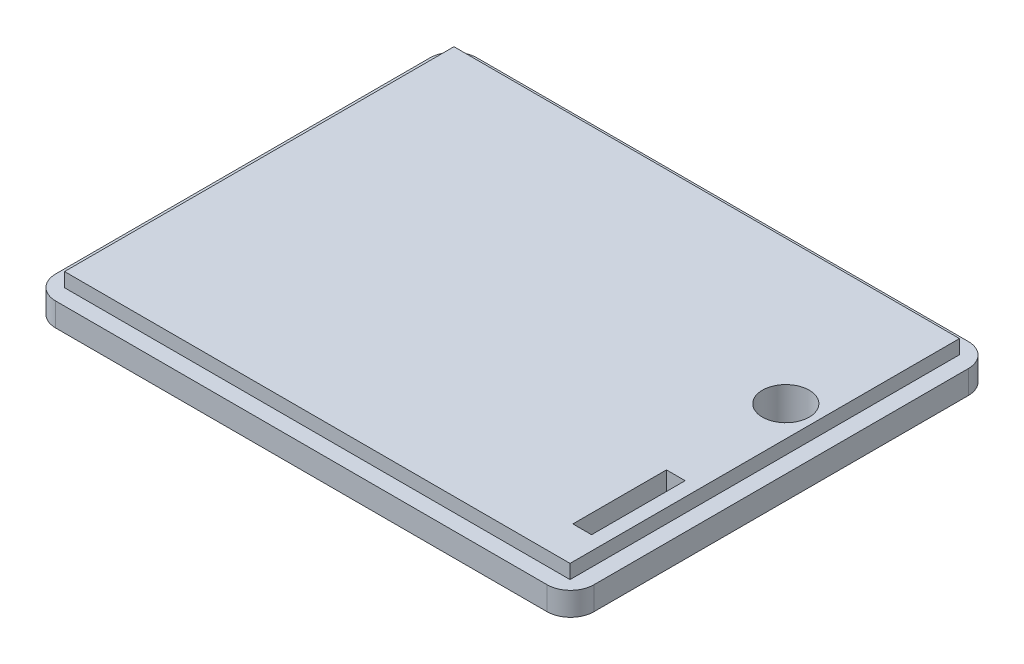
from build123d import *

# Parameters (mm, degrees)
SKETCH1_W           = 115
SKETCH1_H           = 90
BOSS_EXTRUDE1_DEPTH = 5
SKETCH2_W           = 108
SKETCH2_H           = 83.2
BOSS_EXTRUDE2_DEPTH = 3
FILLET1_R           = 5
SKETCH3_W           = 4
SKETCH3_H           = 20
CUT_EXTRUDE1_DEPTH  = 10
FILLET2_R           = 1
SKETCH4_R           = 5
CUT_EXTRUDE2_DEPTH  = 10
FILLET3_R           = 1


with BuildPart() as part:
    # Sketch1 → Boss-Extrude1 (new body)
    with BuildSketch(Plane(origin=(0, 0, 0), x_dir=(1, 0, 0), z_dir=(0, 1, 0))):
        Rectangle(SKETCH1_W, SKETCH1_H)
    extrude(amount=BOSS_EXTRUDE1_DEPTH)

    # Sketch2 → Boss-Extrude2 (add)
    with BuildSketch(Plane(origin=(0, 5, 0), x_dir=(1, 0, 0), z_dir=(0, 1, 0))):
        Rectangle(SKETCH2_W, SKETCH2_H)
    extrude(amount=BOSS_EXTRUDE2_DEPTH)

    # Fillet1
    fillet1_edges = [part.edges().sort_by_distance(p)[0] for p in [
        (57.5, 2.5, 45),
        (-57.5, 2.5, 45),
        (-57.5, 2.5, -45),
        (57.5, 2.5, -45),
    ]]
    fillet(fillet1_edges, radius=FILLET1_R)

    # Sketch3 → Cut-Extrude1 (cut)
    with BuildSketch(Plane(origin=(0, 0, 0), x_dir=(-1, 0, 0), z_dir=(0, -1, 0))):
        with Locations((-49, -24)):
            Rectangle(SKETCH3_W, SKETCH3_H)
    extrude(amount=-CUT_EXTRUDE1_DEPTH, mode=Mode.SUBTRACT)

    # Fillet2
    fillet2_edges = [part.edges().sort_by_distance(p)[0] for p in [
        (47, 0, 24),
        (49, 0, 14),
        (51, 0, 24),
        (49, 0, 34),
    ]]
    fillet(fillet2_edges, radius=FILLET2_R)

    # Sketch4 → Cut-Extrude2 (cut)
    with BuildSketch(Plane.XZ):
        with Locations((47.5, -11)):
            Circle(SKETCH4_R)
    extrude(amount=-CUT_EXTRUDE2_DEPTH, mode=Mode.SUBTRACT)

    # Fillet3
    fillet3_edges = [part.edges().sort_by_distance(p)[0] for p in [
        (42.5, 0, -11),
    ]]
    fillet(fillet3_edges, radius=FILLET3_R)


solid = part.part
